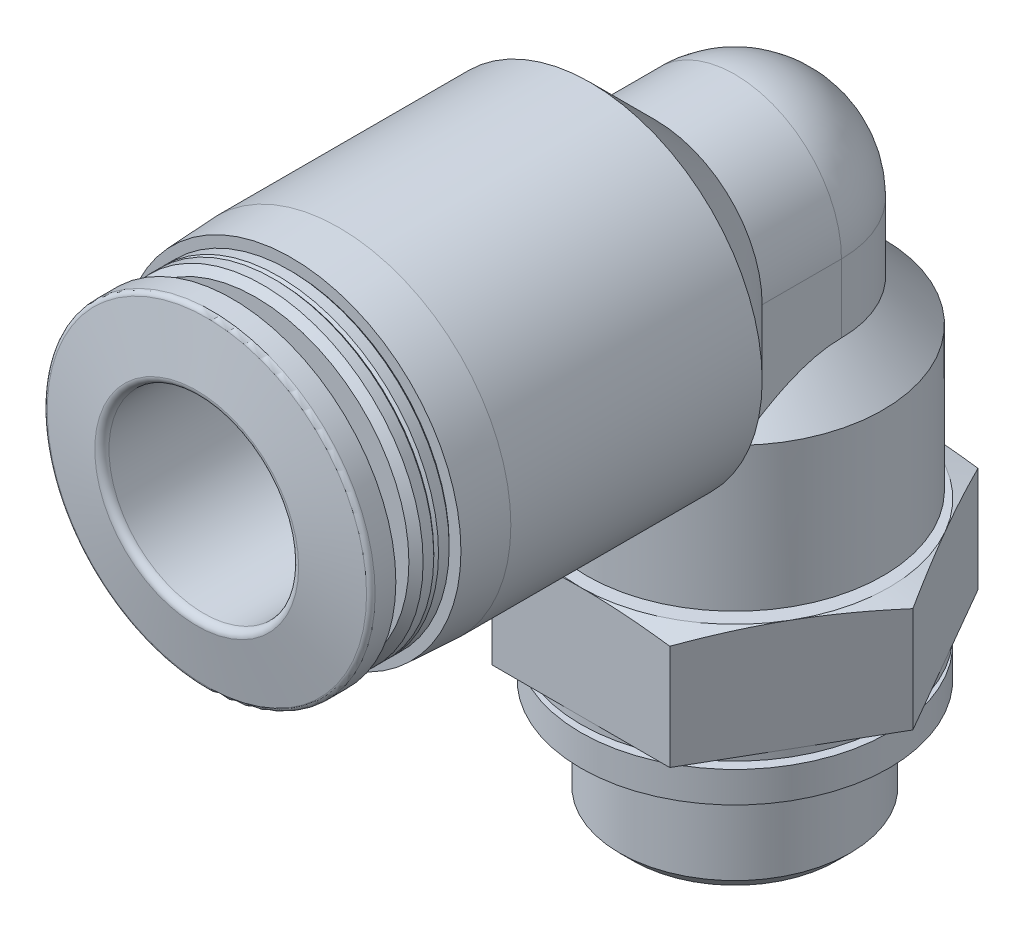
from build123d import *

# Parameters (mm, degrees)
SKIZZE2_W                            = 26
SKIZZE2_H                            = 26
SCHNITT_LINEAR_AUSTRAGEN1_DEPTH      = 4.7
AUFSATZ_LINEAR_AUSTRAGEN1_DEPTH      = 4.64
AUFSATZ_LINEAR_AUSTRAGEN2_DEPTH      = 1
AUFSATZ_LINEAR_AUSTRAGEN2_DEPTH_BACK = 1


with BuildPart() as part:
    # Skizze1 → Rotation1 (revolve)
    with BuildSketch(Plane.XY, mode=Mode.PRIVATE) as rotation1_sk:
        with BuildLine():
            Line((4.495, 17.9), (4.495, 15.015))
            Line((4.495, 15.015), (6.25, 13.26))
            Line((6.25, 13.26), (6.25, 7.2))
            Line((6.25, 7.2), (5.625, 6.9))
            Line((5.625, 6.9), (6.5, 6.9))
            Line((6.5, 6.9), (7.8, 6.55166605))
            Line((7.8, 6.55166605), (7.8, 2.2))
            Line((7.8, 2.2), (6.5, 2.2))
            Line((6.5, 2.2), (6.5, 1.9))
            Line((6.5, 1.9), (6, 1.9))
            Line((6, 1.9), (6, 1.6))
            Line((6, 1.6), (6.5, 1.6))
            Line((6.5, 1.6), (6.5, 0.3))
            Line((6.5, 0.3), (6, 0.3))
            Line((6, 0.3), (6, 0))
            Line((6, 0), (0, 0))
            Line((0, 0), (0, 22.395))
            ThreePointArc((0, 22.395), (3.178444981, 21.078444981), (4.495, 17.9))
        make_face()
    revolve(rotation1_sk.sketch.rotate(Axis((0, 0, 0), (0, 1, 0)), 270), axis=Axis((0, 0, 0), (0, 1, 0)))

    # Skizze2 → Schnitt-Linear austragen1 (cut)
    with BuildSketch(Plane(origin=(0, 2.2, 0), x_dir=(1, 0, 0), z_dir=(0, 1, 0))):
        Rectangle(SKIZZE2_W, SKIZZE2_H)
        Polygon((-7.505553499, 0), (-3.75277675, -6.5), (3.75277675, -6.5), (7.505553499, 0), (3.75277675, 6.5), (-3.75277675, 6.5), align=None, mode=Mode.SUBTRACT)
    extrude(amount=SCHNITT_LINEAR_AUSTRAGEN1_DEPTH, mode=Mode.SUBTRACT)

    # Skizze3 → Rotation2 (revolve)
    with BuildSketch(Plane.XY, mode=Mode.PRIVATE) as rotation2_sk:
        Polygon((0, 0), (4.864, 0), (4.864, -3.619), (4.283, -4.2), (0, -4.2), align=None)
    revolve(rotation2_sk.sketch.rotate(Axis((0, -4.2, 0), (0, 1, 0)), 270), axis=Axis((0, -4.2, 0), (0, 1, 0)))

    # Skizze4 → Rotation3 (revolve)
    with BuildSketch(Plane(origin=(0, 0, 0), x_dir=(0, 0, -1), z_dir=(1, 0, 0)), mode=Mode.PRIVATE) as rotation3_sk:
        with BuildLine():
            Line((-22.7, 17.9), (-22.7, 22.2))
            Line((-22.7, 22.2), (-22.270691475, 24.634729636))
            ThreePointArc((-22.270691475, 24.634729636), (-22.202287446, 24.753208889), (-22.073729924, 24.8))
            Line((-22.073729924, 24.8), (-21.2, 24.8))
            Line((-21.2, 24.8), (-21.2, 22.95))
            ThreePointArc((-21.2, 22.95), (-21.112132034, 22.737867966), (-20.9, 22.65))
            Line((-20.9, 22.65), (-20.2, 22.65))
            Line((-20.2, 22.65), (-20.2, 24.35))
            Line((-20.2, 24.35), (-19.9, 24.65))
            Line((-19.9, 24.65), (-19.45, 24.65))
            Line((-19.45, 24.65), (-19.35, 24.55))
            Line((-19.35, 24.55), (-19.25, 24.65))
            Line((-19.25, 24.65), (-18.8, 24.65))
            Line((-18.8, 24.65), (-18.7, 24.55))
            Line((-18.7, 24.55), (-18.7, 25.045184441))
            Line((-18.7, 25.045184441), (-16.7, 25.15))
            Line((-16.7, 25.15), (-6.1, 25.15))
            Line((-6.1, 25.15), (-3.345, 22.395))
            Line((-3.345, 22.395), (0, 22.395))
            Line((0, 22.395), (0, 17.9))
            Line((0, 17.9), (-22.7, 17.9))
        make_face()
    revolve(rotation3_sk.sketch.rotate(Axis((0, 17.9, 0), (0, 0, 1)), 270), axis=Axis((0, 17.9, 0), (0, 0, 1)))

    # Skizze5 → Aufsatz-Linear austragen1 (add)
    with BuildSketch(Plane(origin=(0, 17.9, 0), x_dir=(1, 0, 0), z_dir=(0, 1, 0))):
        with BuildLine():
            Line((4.495, -4.34251943), (4.495, 0))
            Line((4.495, 0), (-4.495, 0))
            Line((-4.495, 0), (-4.495, -4.34251943))
            ThreePointArc((-4.495, -4.34251943), (0, -6.25), (4.495, -4.34251943))
        make_face()
    extrude(amount=-AUFSATZ_LINEAR_AUSTRAGEN1_DEPTH)

    # Skizze6 → Aufsatz-Linear austragen2 (add, two sides)
    with BuildSketch(Plane(origin=(0, 0, 0), x_dir=(0, 0, -1), z_dir=(1, 0, 0))) as aufsatz_linear_austragen2_sk:
        Polygon((-11.325, 14.275), (-3.125, 6.075), (-3.125, 14.275), align=None)
    extrude(amount=AUFSATZ_LINEAR_AUSTRAGEN2_DEPTH)
    extrude(aufsatz_linear_austragen2_sk.sketch, amount=-AUFSATZ_LINEAR_AUSTRAGEN2_DEPTH_BACK)

    # Skizze7 → Schnitt-Rotation1 (revolve, cut)
    with BuildSketch(Plane.XY, mode=Mode.PRIVATE) as schnitt_rotation1_sk:
        Polygon((0, 17.9), (3, 17.9), (3, -2.1), (3.242666667, -2.1), (3.242666667, -3.7), (3.742666667, -4.2), (0, -4.2), align=None)
    revolve(schnitt_rotation1_sk.sketch.rotate(Axis((0, -4.2, 0), (0, 1, 0)), 270), axis=Axis((0, -4.2, 0), (0, 1, 0)), mode=Mode.SUBTRACT)

    # Skizze8 → Schnitt-Rotation2 (revolve, cut)
    with BuildSketch(Plane(origin=(0, 0, 0), x_dir=(0, 0, -1), z_dir=(1, 0, 0)), mode=Mode.PRIVATE) as schnitt_rotation2_sk:
        with BuildLine():
            Line((-22.7, 17.9), (-22.7, 22.2))
            ThreePointArc((-22.7, 22.2), (-22.612132034, 21.987867966), (-22.4, 21.9))
            Line((-22.4, 21.9), (-4.6, 21.9))
            Line((-4.6, 21.9), (-4.6, 20.9))
            Line((-4.6, 20.9), (0, 20.9))
            ThreePointArc((0, 20.9), (2.121320344, 20.021320344), (3, 17.9))
            Line((3, 17.9), (-22.7, 17.9))
        make_face()
    revolve(schnitt_rotation2_sk.sketch.rotate(Axis((0, 17.9, 0), (0, 0, 1)), 270), axis=Axis((0, 17.9, 0), (0, 0, 1)), mode=Mode.SUBTRACT)


solid = part.part
